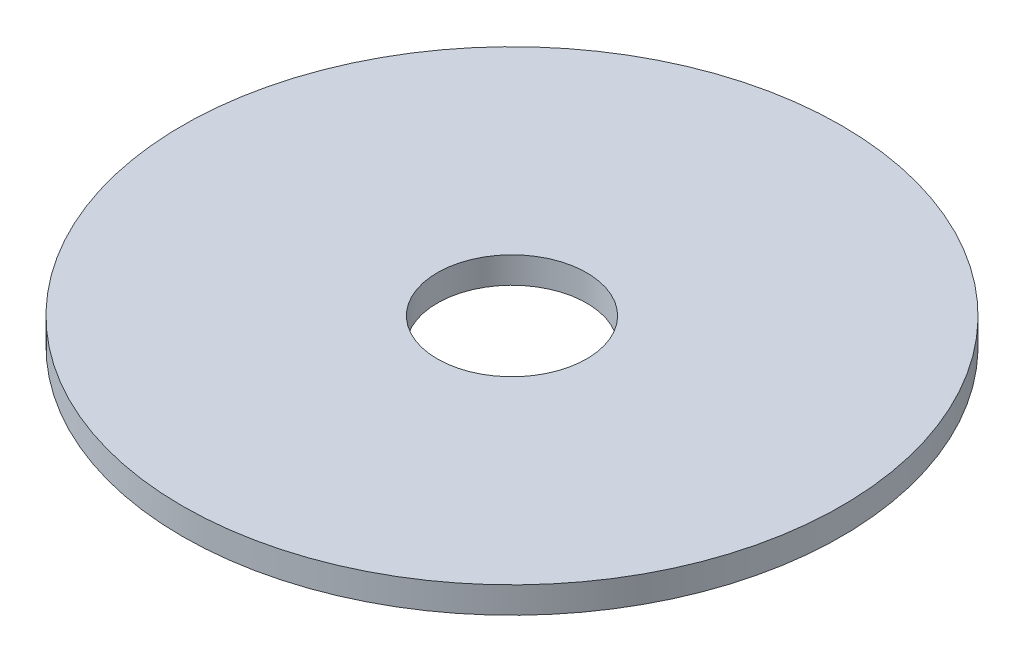
from build123d import *

# Parameters (mm, degrees)
SKETCH1_R           = 9.525
SKETCH1_R_2         = 2.159
BOSS_EXTRUDE1_DEPTH = 0.762


with BuildPart() as part:
    # Sketch1 → Boss-Extrude1 (new body)
    with BuildSketch(Plane(origin=(0, 0, 0), x_dir=(1, 0, 0), z_dir=(0, 1, 0))):
        Circle(SKETCH1_R)
        Circle(SKETCH1_R_2, mode=Mode.SUBTRACT)
    extrude(amount=BOSS_EXTRUDE1_DEPTH)


solid = part.part
